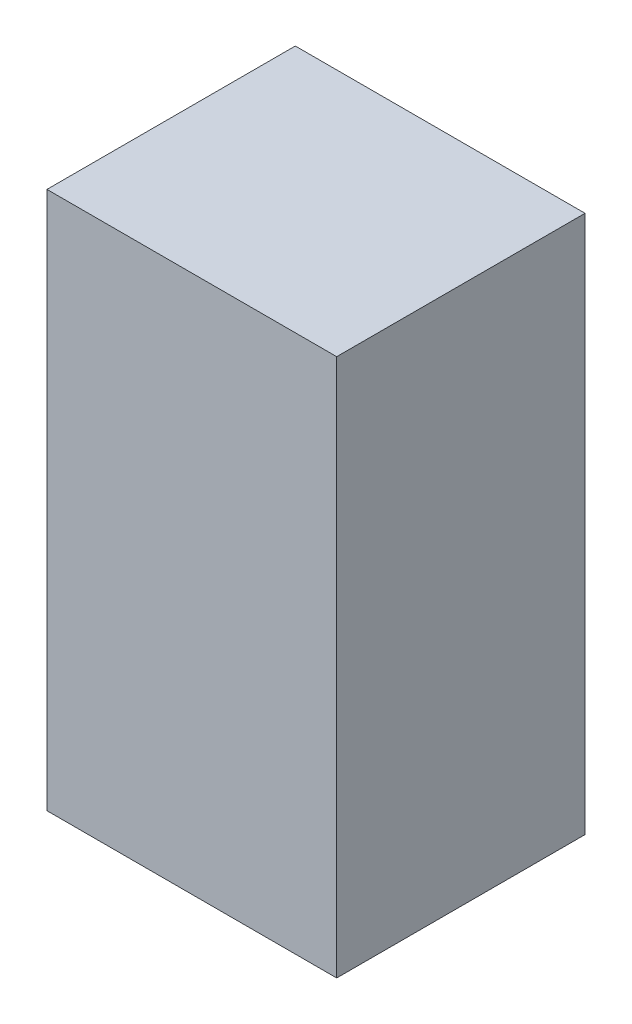
from build123d import *

# Parameters (mm, degrees)
SKETCH1_W           = 69.999999954
SKETCH1_H           = 130.000000096
BOSS_EXTRUDE1_DEPTH = 60


with BuildPart() as part:
    # Sketch1 → Boss-Extrude1 (new body)
    with BuildSketch(Plane.XY):
        with Locations((-392.808695629, 314.895652126)):
            Rectangle(SKETCH1_W, SKETCH1_H)
    extrude(amount=BOSS_EXTRUDE1_DEPTH)


solid = part.part
